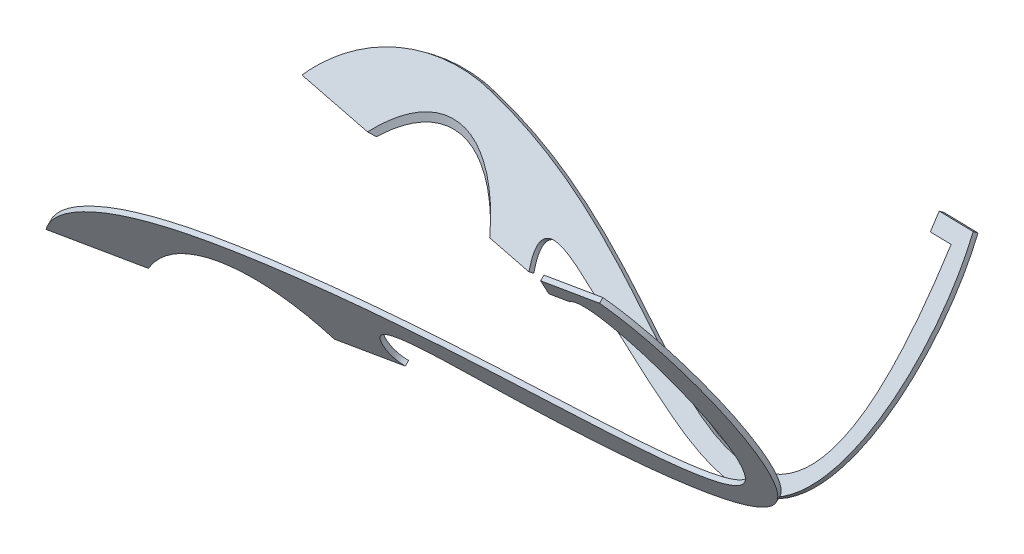
from build123d import *

# Parameters (mm, degrees)
BOSS_EXTRUDE1_DEPTH = 10
SKETCH8_OUTSIDE_W   = 1921.676
SKETCH8_OUTSIDE_H   = 1028.983
CUT_EXTRUDE3_DEPTH  = 10
BOSS_EXTRUDE2_DEPTH = 10
SKETCH6_R           = 250
CUT_EXTRUDE4_DEPTH  = 500


with BuildPart() as part:
    # Sketch4 → Boss-Extrude1 (new body)
    with BuildSketch(Plane(origin=(25.41607215, -85.420801185, -123.707721823), x_dir=(-0.986007921, -0.094719198, -0.137173803), z_dir=(0.166698467, -0.56025638, -0.811371931))):
        Polygon((317.32228266, 104.938265095), (317.182061177, 333.172017332), (-846.559058733, 176.882823879), (-846.559058733, 500.38648882), (-1200.909701142, 500.38648882), (-1200.909701142, -98.958673977), align=None)
    extrude(amount=BOSS_EXTRUDE1_DEPTH)

    # Sketch8 outside → Cut-Extrude3 (cut)
    with BuildSketch(Plane(origin=(25.41607215, -85.420801185, -123.707721823), x_dir=(0.985869296, 0.108504049, 0.127626814), z_dir=(-0.166698467, 0.56025638, 0.811371931))):
        with Locations((458.963, 225.2185)):
            Rectangle(SKETCH8_OUTSIDE_W, SKETCH8_OUTSIDE_H)
        with BuildLine():
            Line((-309.911410321, 160.83928307), (272.834648071, 86.025674387))
            add(Edge.make_bspline(
                [(272.834648071, 86.025674387), (243.681808365, 172.787493134), (445.517597615, 96.259199427), (611.628780577, 25.931837343), (1024.918435384, -108.426106267), (1099.692227504, 306.774979851), (1071.194585257, 470.32404794)],
                knots=[0, 0, 0, 0, 0.133860158, 0.347766727, 0.574790643, 1, 1, 1, 1], degree=3))
            Line((1071.194585257, 470.32404794), (991.29921302, 470.32404794))
            Line((991.29921302, 470.32404794), (991.29921302, 437.680440221))
            Line((991.29921302, 437.680440221), (1040.297840373, 437.680440221))
            add(Edge.make_bspline(
                [(29.10210173, 286.865318935), (182.94722743, 265.067722456), (564.8741301, 132.414588145), (1050.427735798, -192.059038484), (1040.297840373, 437.680440221)],
                knots=[0, 0, 0, 0, 0.337700707, 1, 1, 1, 1], degree=3))
            add(Edge.make_bspline(
                [(29.10210173, 286.865318935), (-194.132225074, 309.512141885), (-309.911410321, 160.83928307)],
                knots=[4.71238898, 4.71238898, 4.71238898, 5.820352374, 5.820352374, 5.820352374], degree=2, weights=[1, 0.850436587, 1]))
        make_face(mode=Mode.SUBTRACT)
    extrude(amount=-CUT_EXTRUDE3_DEPTH, mode=Mode.SUBTRACT)


with BuildPart() as body_2:
    # Sketch9 → Boss-Extrude2 (new body)
    with BuildSketch(Plane(origin=(28.849780749, -76.397649989, 140.420621664), x_dir=(0.984041186, 0.075080082, -0.161325526), z_dir=(0.177602325, -0.470312075, 0.864444311))):
        with BuildLine():
            Line((-161.1926824, 100.64818617), (286.867133856, 62.390088681))
            add(Edge.make_bspline(
                [(286.867133856, 62.390088681), (265.54532093, 75.395872765), (255.125848311, 200.914987993), (584.409158079, 9.205364905), (1075.12625979, -132.985267573), (913.157082834, 415.212058693), (813.013138342, 513.9816876)],
                knots=[0, 0, 0, 0, 0.058611779, 0.210635663, 0.589849874, 1, 1, 1, 1], degree=3))
            Line((813.013138342, 513.9816876), (712.493416551, 522.564678478))
            Line((712.493416551, 522.564678478), (712.493416551, 486.640847166))
            Line((712.493416551, 486.640847166), (748.075080552, 483.602666278))
            add(Edge.make_bspline(
                [(-326.001643727, 114.720586953), (-290.613838315, 180.766558311), (-153.848452213, 273.753264413), (56.890330865, 268.97337602), (305.548047374, 213.935356191), (518.043678788, 127.646601347), (1051.065910492, -106.50163366), (808.062166758, 530.351568219), (748.075080552, 483.602666278)],
                knots=[0, 0, 0, 0, 0.124853707, 0.265736928, 0.349320784, 0.553048555, 0.73506829, 1, 1, 1, 1], degree=3))
            Line((-326.001643727, 114.720586953), (-161.1926824, 100.64818617))
        make_face()
    extrude(amount=BOSS_EXTRUDE2_DEPTH)


with BuildPart() as cut_extrude4_tool:
    # Sketch6 → Cut-Extrude4 (new body, symmetric)
    with BuildSketch(Plane(origin=(0, 0, 0), x_dir=(1, 0, 0), z_dir=(0, 1, 0))):
        Circle(SKETCH6_R)
    extrude(amount=CUT_EXTRUDE4_DEPTH, both=True)


with BuildPart() as part_1:
    add(part.part)

    # Cut-Extrude4: cut by cut_extrude4_tool
    add(cut_extrude4_tool.part, mode=Mode.SUBTRACT)


with BuildPart() as body_2_1:
    add(body_2.part)

    # Cut-Extrude4: cut by cut_extrude4_tool
    add(cut_extrude4_tool.part, mode=Mode.SUBTRACT)


solid = Compound([part_1.part, body_2_1.part])
